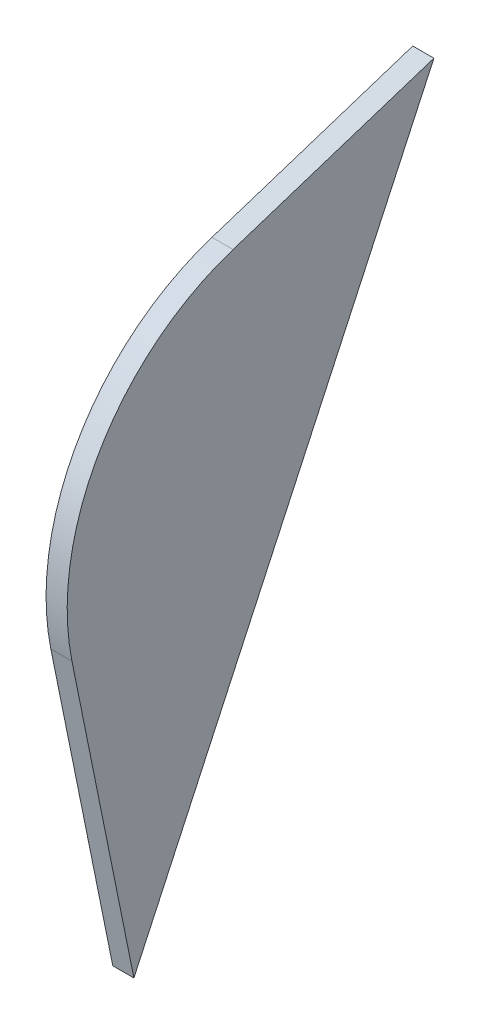
from build123d import *

# Parameters (mm, degrees)
SALIENTE_EXTRUIR1_DEPTH = 3


with BuildPart() as part:
    # Croquis1 → Saliente-Extruir1 (new body)
    with BuildSketch(Plane(origin=(0, 0, 0), x_dir=(0, 0, -1), z_dir=(1, 0, 0))):
        with BuildLine():
            Line((8.78519689, 25.518100679), (37.317461794, 34.786857846))
            Line((37.317461794, 34.786857846), (-5.303202755, -57.060190641))
            Line((-5.303202755, -57.060190641), (-14.098651329, -13.690578432))
            ThreePointArc((-14.098651329, -13.690578432), (-10.129936354, 10.27544296), (8.78519689, 25.518100679))
        make_face()
    extrude(amount=SALIENTE_EXTRUIR1_DEPTH)


solid = part.part
